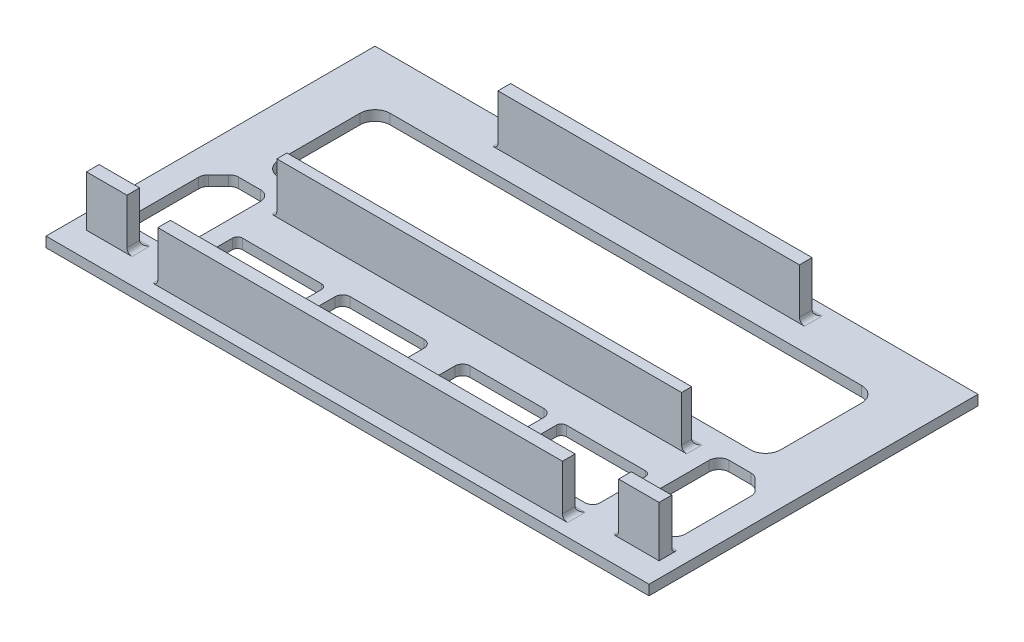
from build123d import *

# Parameters (mm, degrees)
SKETCH1_W           = 119.2
SKETCH1_H           = 65.04
BOSS_EXTRUDE1_DEPTH = 2
SKETCH2_W           = 59.6
SKETCH2_H           = 2.5
SKETCH2_W_2         = 80
SKETCH2_H_2         = 2
BOSS_EXTRUDE2_DEPTH = 10
FILLET1_R           = 1
SKETCH4_W           = 80
SKETCH4_H           = 2.5
SKETCH4_W_2         = 8
BOSS_EXTRUDE3_DEPTH = 10
FILLET2_R           = 1
FILLET3_R           = 1
CUT_EXTRUDE2_DEPTH  = 10
CUT_EXTRUDE3_DEPTH  = 10


with BuildPart() as part:
    # Sketch1 → Boss-Extrude1 (new body)
    with BuildSketch(Plane(origin=(0, 0, 0), x_dir=(1, 0, 0), z_dir=(0, 1, 0))):
        Rectangle(SKETCH1_W, SKETCH1_H)
    extrude(amount=BOSS_EXTRUDE1_DEPTH)

    # Sketch2 → Boss-Extrude2 (add)
    with BuildSketch(Plane(origin=(0, 2, 0), x_dir=(1, 0, 0), z_dir=(0, 1, 0))):
        with Locations((0, 28.27)):
            Rectangle(SKETCH2_W, SKETCH2_H)
        with Locations((0, -5.48)):
            Rectangle(SKETCH2_W_2, SKETCH2_H_2)
    extrude(amount=BOSS_EXTRUDE2_DEPTH)

    # Fillet1
    fillet1_edges = [part.edges().sort_by_distance(p)[0] for p in [
        (40, 2, 5.48),
        (0, 2, 4.48),
        (-40, 2, 5.48),
        (-29.8, 2, -28.27),
        (29.8, 2, -28.27),
        (0, 2, -29.52),
    ]]
    fillet(fillet1_edges, radius=FILLET1_R)

    # Sketch4 → Boss-Extrude3 (add)
    with BuildSketch(Plane(origin=(0, 2, 0), x_dir=(1, 0, 0), z_dir=(0, 1, 0))):
        with Locations((0, -28.77)):
            Rectangle(SKETCH4_W, SKETCH4_H)
        with Locations((52.6, -26.27)):
            Rectangle(SKETCH4_W_2, SKETCH4_H)
    boss_extrude3 = extrude(amount=BOSS_EXTRUDE3_DEPTH)

    # Fillet2
    fillet2_edges = [part.edges().sort_by_distance(p)[0] for p in [
        (-40, 2, 28.77),
        (48.6, 2, 26.27),
        (52.6, 2, 25.02),
        (40, 2, 28.77),
        (0, 2, 27.52),
    ]]
    fillet(fillet2_edges, radius=FILLET2_R)

    # Mirror1: Boss-Extrude3 across plane
    add(boss_extrude3.mirror(Plane.ZY))

    # Fillet3
    fillet3_edges = [part.edges().sort_by_distance(p)[0] for p in [
        (-48.6, 2, 26.27),
        (-52.6, 2, 25.02),
    ]]
    fillet(fillet3_edges, radius=FILLET3_R)

    # Sketch5 → Cut-Extrude2 (cut)
    with BuildSketch(Plane(origin=(0, 2, 0), x_dir=(1, 0, 0), z_dir=(0, 1, 0))):
        with BuildLine():
            Line((46.6, 22.52), (6.311514948, 22.52))
            Line((6.311514948, 22.52), (-46.6, 22.52))
            ThreePointArc((-46.6, 22.52), (-48.721320344, 21.641320344), (-49.6, 19.52))
            Line((-49.6, 19.52), (-49.6, 3.52))
            ThreePointArc((-49.6, 3.52), (-48.721320344, 1.398679656), (-46.6, 0.52))
            Line((-46.6, 0.52), (46.6, 0.52))
            ThreePointArc((46.6, 0.52), (48.721320344, 1.398679656), (49.6, 3.52))
            Line((49.6, 3.52), (49.6, 19.52))
            ThreePointArc((49.6, 19.52), (48.721320344, 21.641320344), (46.6, 22.52))
        make_face()
    extrude(amount=-CUT_EXTRUDE2_DEPTH, mode=Mode.SUBTRACT)

    # Sketch6 → Cut-Extrude3 (cut)
    with BuildSketch(Plane(origin=(0, 2, 0), x_dir=(1, 0, 0), z_dir=(0, 1, 0))):
        with BuildLine():
            Line((54.014213562, -5.94084617), (52.045315698, -3.971948306))
            ThreePointArc((52.045315698, -3.971948306), (51.396469, -3.538402803), (50.631102135, -3.386161868))
            Line((50.631102135, -3.386161868), (46.32782558, -3.386161868))
            ThreePointArc((46.32782558, -3.386161868), (44.913612017, -3.971948306), (44.32782558, -5.386161868))
            Line((44.32782558, -5.386161868), (44.32782558, -20.397912268))
            ThreePointArc((44.32782558, -20.397912268), (44.913612017, -21.812125831), (46.32782558, -22.397912268))
            Line((46.32782558, -22.397912268), (52.6, -22.397912268))
            ThreePointArc((52.6, -22.397912268), (54.014213562, -21.812125831), (54.6, -20.397912268))
            Line((54.6, -20.397912268), (54.6, -7.355059733))
            ThreePointArc((54.6, -7.355059733), (54.447759065, -6.589692868), (54.014213562, -5.94084617))
        make_face()
        with BuildLine():
            Line((39.82782558, -13.44932419), (24.210760832, -13.44932419))
            ThreePointArc((24.210760832, -13.44932419), (23.503654051, -13.742217409), (23.210760832, -14.44932419))
            Line((23.210760832, -14.44932419), (23.210760832, -23.393622011))
            ThreePointArc((23.210760832, -23.393622011), (23.650100661, -24.454282183), (24.710760832, -24.893622011))
            Line((24.710760832, -24.893622011), (39.32782558, -24.893622011))
            ThreePointArc((39.32782558, -24.893622011), (40.388485752, -24.454282183), (40.82782558, -23.393622011))
            Line((40.82782558, -23.393622011), (40.82782558, -14.44932419))
            ThreePointArc((40.82782558, -14.44932419), (40.534932361, -13.742217409), (39.82782558, -13.44932419))
        make_face()
        with BuildLine():
            Line((4.043952302, -24.893622011), (19.660852384, -24.893622011))
            ThreePointArc((19.660852384, -24.893622011), (20.367959165, -24.600728792), (20.660852384, -23.893622011))
            Line((20.660852384, -23.893622011), (20.660852384, -14.321364431))
            ThreePointArc((20.660852384, -14.321364431), (20.221512556, -13.260704259), (19.160852384, -12.821364431))
            Line((19.160852384, -12.821364431), (4.543952302, -12.821364431))
            ThreePointArc((4.543952302, -12.821364431), (3.48329213, -13.260704259), (3.043952302, -14.321364431))
            Line((3.043952302, -14.321364431), (3.043952302, -23.893622011))
            ThreePointArc((3.043952302, -23.893622011), (3.336845521, -24.600728792), (4.043952302, -24.893622011))
        make_face()
        with BuildLine():
            Line((-4.043952302, -24.893622011), (-19.660852384, -24.893622011))
            ThreePointArc((-19.660852384, -24.893622011), (-20.367959165, -24.600728792), (-20.660852384, -23.893622011))
            Line((-20.660852384, -23.893622011), (-20.660852384, -14.321364431))
            ThreePointArc((-20.660852384, -14.321364431), (-20.221512556, -13.260704259), (-19.160852384, -12.821364431))
            Line((-19.160852384, -12.821364431), (-4.543952302, -12.821364431))
            ThreePointArc((-4.543952302, -12.821364431), (-3.48329213, -13.260704259), (-3.043952302, -14.321364431))
            Line((-3.043952302, -14.321364431), (-3.043952302, -23.893622011))
            ThreePointArc((-3.043952302, -23.893622011), (-3.336845521, -24.600728792), (-4.043952302, -24.893622011))
        make_face()
        with BuildLine():
            Line((-39.32782558, -24.893622011), (-24.710760832, -24.893622011))
            ThreePointArc((-24.710760832, -24.893622011), (-23.650100661, -24.454282183), (-23.210760832, -23.393622011))
            Line((-23.210760832, -23.393622011), (-23.210760832, -14.44932419))
            ThreePointArc((-23.210760832, -14.44932419), (-23.503654051, -13.742217409), (-24.210760832, -13.44932419))
            Line((-24.210760832, -13.44932419), (-39.82782558, -13.44932419))
            ThreePointArc((-39.82782558, -13.44932419), (-40.534932361, -13.742217409), (-40.82782558, -14.44932419))
            Line((-40.82782558, -14.44932419), (-40.82782558, -23.393622011))
            ThreePointArc((-40.82782558, -23.393622011), (-40.388485752, -24.454282183), (-39.32782558, -24.893622011))
        make_face()
        with BuildLine():
            Line((-44.32782558, -5.386161868), (-44.32782558, -20.397912268))
            ThreePointArc((-44.32782558, -20.397912268), (-44.913612017, -21.812125831), (-46.32782558, -22.397912268))
            Line((-46.32782558, -22.397912268), (-52.6, -22.397912268))
            ThreePointArc((-52.6, -22.397912268), (-54.014213562, -21.812125831), (-54.6, -20.397912268))
            Line((-54.6, -20.397912268), (-54.6, -7.355059733))
            ThreePointArc((-54.6, -7.355059733), (-54.447759065, -6.589692868), (-54.014213562, -5.94084617))
            Line((-54.014213562, -5.94084617), (-52.045315698, -3.971948306))
            ThreePointArc((-52.045315698, -3.971948306), (-51.396469, -3.538402803), (-50.631102135, -3.386161868))
            Line((-50.631102135, -3.386161868), (-46.32782558, -3.386161868))
            ThreePointArc((-46.32782558, -3.386161868), (-44.913612017, -3.971948306), (-44.32782558, -5.386161868))
        make_face()
    extrude(amount=-CUT_EXTRUDE3_DEPTH, mode=Mode.SUBTRACT)


solid = part.part
